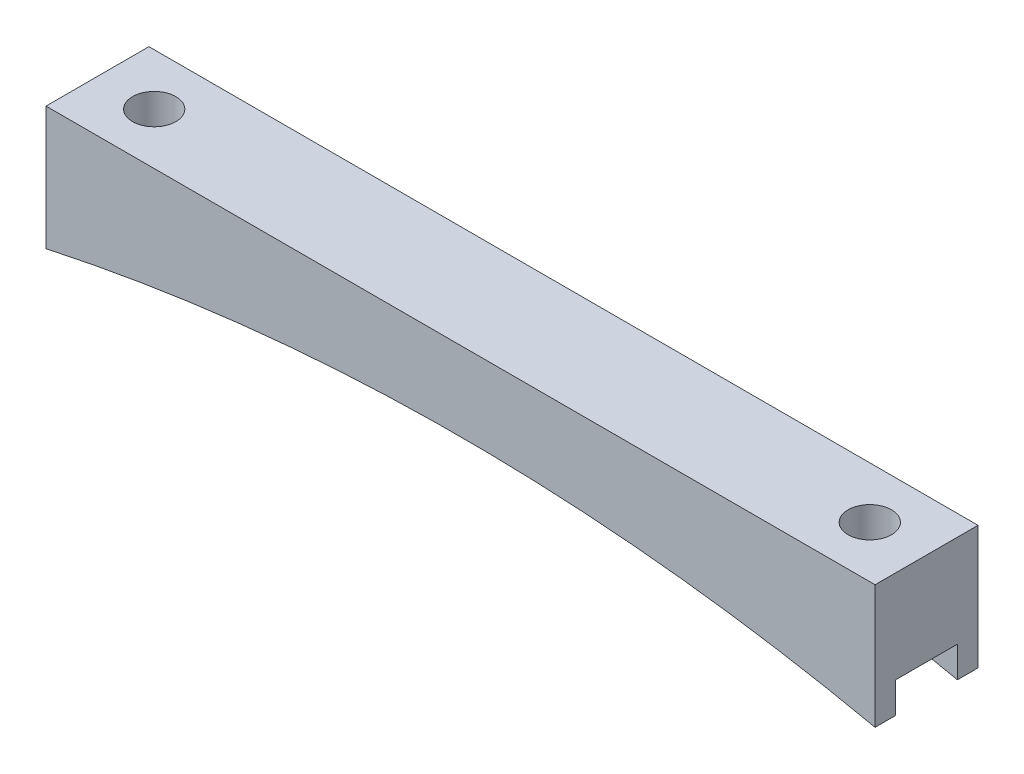
from build123d import *

# Parameters (mm, degrees)
BOSS_EXTRUDE1_DEPTH = 12.7
SKETCH2_R           = 2.675
CUT_EXTRUDE1_DEPTH  = 16.24
SKETCH3_W           = 7.62
SKETCH3_H           = 3.81
CUT_EXTRUDE2_DEPTH  = 103.2900001


with BuildPart() as part:
    # Sketch1 → Boss-Extrude1 (new body)
    with BuildSketch(Plane.XY):
        with BuildLine():
            Line((-51.145, 0), (51.145, 0))
            Line((51.145, 0), (51.145, -15.24))
            ThreePointArc((51.145, -15.24), (0, -9.757469614), (-51.145, -15.24))
            Line((-51.145, -15.24), (-51.145, 0))
        make_face()
    extrude(amount=BOSS_EXTRUDE1_DEPTH)

    # Sketch2 → Cut-Extrude1 (cut, through all)
    with BuildSketch(Plane(origin=(0, 0, 0), x_dir=(1, 0, 0), z_dir=(0, 1, 0))):
        with Locations((-44.145, -6.35)):
            Circle(SKETCH2_R)
        with Locations((44.145, -6.35)):
            Circle(SKETCH2_R)
    extrude(amount=-CUT_EXTRUDE1_DEPTH, mode=Mode.SUBTRACT)

    # Sketch3 → Cut-Extrude2 (cut, through all)
    with BuildSketch(Plane(origin=(51.145, 0, 0), x_dir=(0, 0, -1), z_dir=(1, 0, 0))):
        with Locations((-6.35, -13.335)):
            Rectangle(SKETCH3_W, SKETCH3_H)
    extrude(amount=-CUT_EXTRUDE2_DEPTH, mode=Mode.SUBTRACT)


solid = part.part
